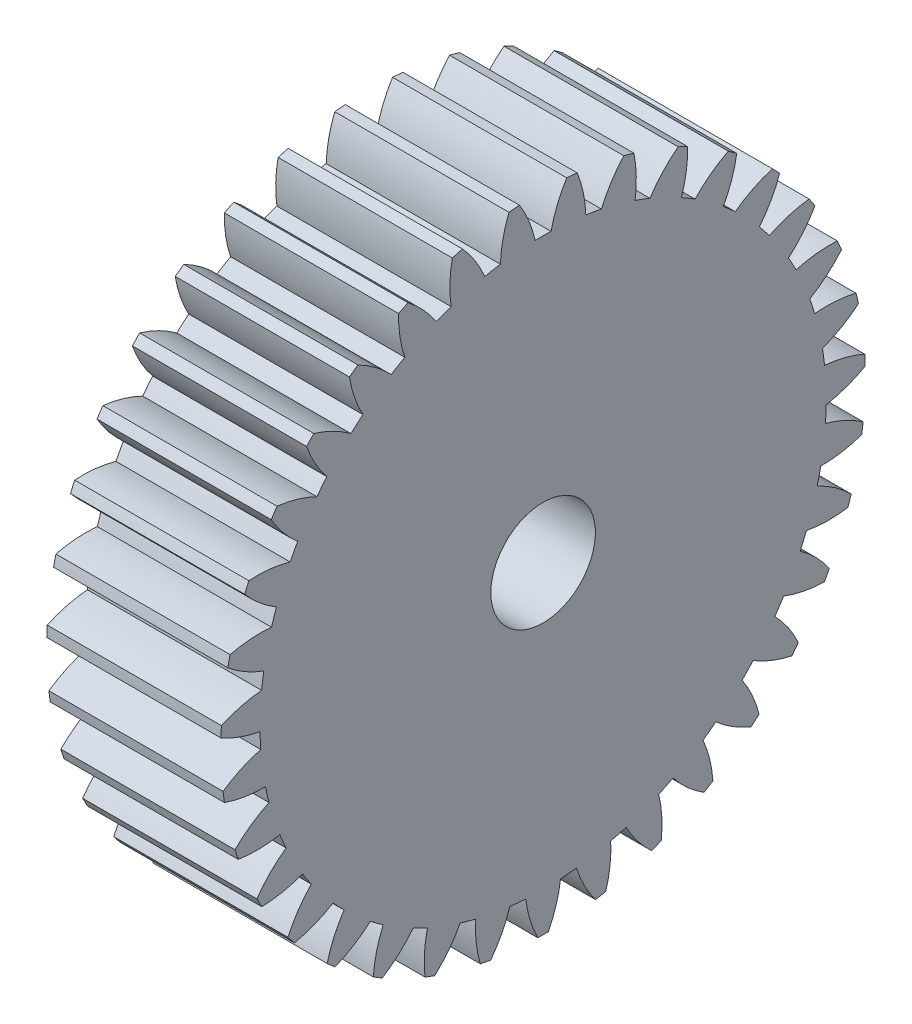
from build123d import *

# Parameters (mm, degrees)
BASPROSKE_W     = 10
BASPROSKE_H     = 18.5
TOOTHCUT_DEPTH  = 29.008927148
TEETHCUTS_COUNT = 35
TEETHCUTS_ANGLE = 349.714285714
BORSKE_R        = 3
BORE_DEPTH      = 50.0000508


with BuildPart() as part:
    # BasProSke → Base-Revolve (revolve)
    with BuildSketch(Plane(origin=(0, 0, 0), x_dir=(1, 0, 0), z_dir=(0, 1, 0)), mode=Mode.PRIVATE) as base_revolve_sk:
        with Locations((5, 9.25)):
            Rectangle(BASPROSKE_W, BASPROSKE_H)
    revolve(base_revolve_sk.sketch.rotate(Axis((-10, 0, 0), (1, 0, 0)), 180), axis=Axis((-10, 0, 0), (1, 0, 0)))

    # TooCutSke → ToothCut (cut, through all)
    with BuildSketch(Plane(origin=(0, 0, 0), x_dir=(0, 0, -1), z_dir=(1, 0, 0))):
        with BuildLine():
            ThreePointArc((0.456361119, 16.242590173), (0, 16.249), (-0.456361119, 16.242590173))
            ThreePointArc((-0.456361119, 16.242590173), (-0.817781123, 17.39831105), (-1.372969849, 18.474452602))
            ThreePointArc((-1.372969849, 18.474452602), (0, 18.5254), (1.372969849, 18.474452602))
            ThreePointArc((1.372969849, 18.474452602), (0.817781123, 17.39831105), (0.456361119, 16.242590173))
        make_face()
    toothcut = extrude(amount=TOOTHCUT_DEPTH, mode=Mode.SUBTRACT)

    # TeethCuts: ToothCut ×35 about axis
    teethcuts_axis = Axis((-10, 0, 0), (1, 0, 0))
    for i in range(1, TEETHCUTS_COUNT):
        add(toothcut.rotate(teethcuts_axis, i * TEETHCUTS_ANGLE / (TEETHCUTS_COUNT - 1)), mode=Mode.SUBTRACT)

    # BorSke → Bore (cut, symmetric)
    with BuildSketch(Plane(origin=(0, 0, 0), x_dir=(0, 0, -1), z_dir=(1, 0, 0))):
        with Locations(Location((0, 0, 0), (0, 0, 180))):
            Circle(BORSKE_R)
    extrude(amount=BORE_DEPTH, both=True, mode=Mode.SUBTRACT)


solid = part.part
